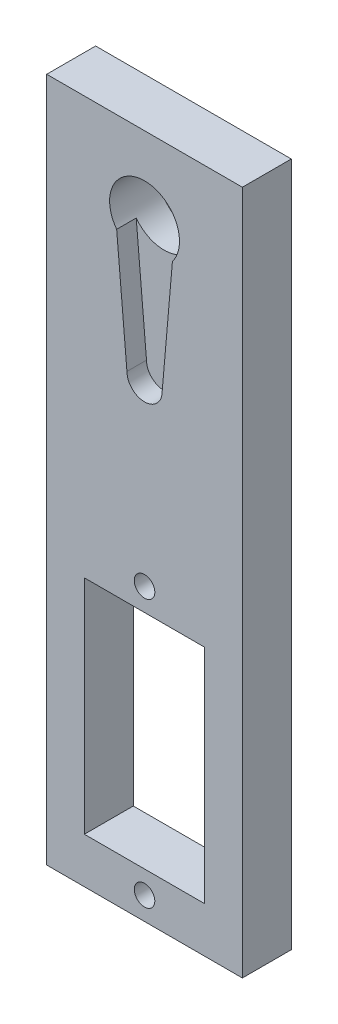
from build123d import *

# Parameters (mm, degrees)
SKETCH3_W           = 20
SKETCH3_H           = 70
BOSS_EXTRUDE3_DEPTH = 5
CUT_EXTRUDE2_DEPTH  = 2
SKETCH6_R           = 3.57
CUT_EXTRUDE3_DEPTH  = 3
SKETCH7_R           = 1.05
SKETCH7_W           = 12.3
SKETCH7_H           = 22.7
CUT_EXTRUDE4_DEPTH  = 5


with BuildPart() as part:
    # Sketch3 → Boss-Extrude3 (new body)
    with BuildSketch(Plane.XY):
        Rectangle(SKETCH3_W, SKETCH3_H)
    extrude(amount=BOSS_EXTRUDE3_DEPTH)

    # Sketch4 → Cut-Extrude2 (cut)
    with BuildSketch(Plane.XY.offset(5)):
        with BuildLine():
            Line((-2.85, 24.850023256), (-1.8, 12.795667197))
            Line((-1.8, 12.795667197), (1.8, 12.795667197))
            Line((1.8, 12.795667197), (2.85, 24.850023256))
            ThreePointArc((2.85, 24.850023256), (0, 23.43), (-2.85, 24.850023256))
        make_face()
        with BuildLine():
            Line((1.8, 12.795667197), (-1.8, 12.795667197))
            ThreePointArc((-1.8, 12.795667197), (0, 10.995667197), (1.8, 12.795667197))
        make_face()
        with BuildLine():
            ThreePointArc((3.57, 27), (-1.133666618, 30.385217866), (-2.85, 24.850023256))
            Line((-2.85, 24.850023256), (2.85, 24.850023256))
            ThreePointArc((2.85, 24.850023256), (3.385217866, 25.866333382), (3.57, 27))
        make_face()
        with BuildLine():
            Line((2.85, 24.850023256), (-2.85, 24.850023256))
            ThreePointArc((-2.85, 24.850023256), (0, 23.43), (2.85, 24.850023256))
        make_face()
    extrude(amount=-CUT_EXTRUDE2_DEPTH, mode=Mode.SUBTRACT)

    # Sketch6 → Cut-Extrude3 (cut)
    with BuildSketch(Plane.XY.offset(3)):
        with Locations((0, 27)):
            Circle(SKETCH6_R)
    extrude(amount=-CUT_EXTRUDE3_DEPTH, mode=Mode.SUBTRACT)

    # Sketch7 → Cut-Extrude4 (cut)
    with BuildSketch(Plane.XY.offset(5)):
        with Locations((0, -5.33)):
            Circle(SKETCH7_R)
        with Locations((0, -32.67)):
            Circle(SKETCH7_R)
        with Locations((0, -19)):
            Rectangle(SKETCH7_W, SKETCH7_H)
    extrude(amount=-CUT_EXTRUDE4_DEPTH, mode=Mode.SUBTRACT)


solid = part.part
